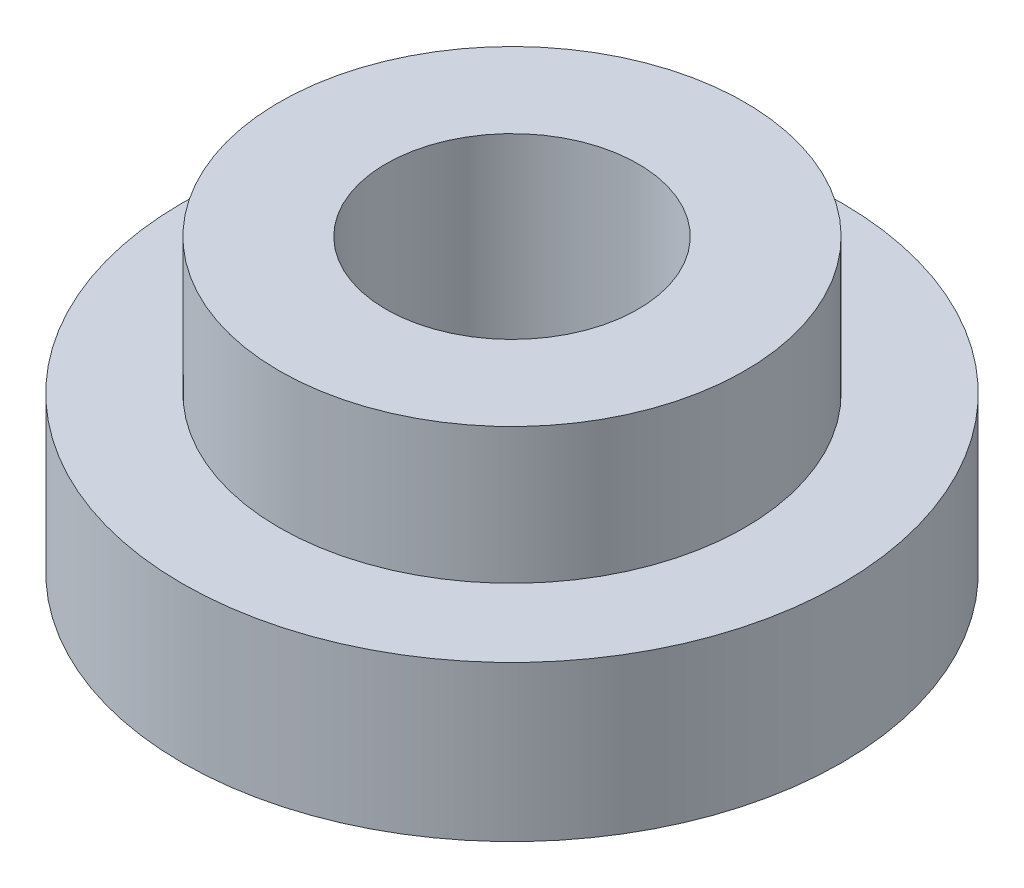
from build123d import *

# Parameters (mm, degrees)
SKETCH1_R           = 4.318
BOSS_EXTRUDE1_DEPTH = 2.032
SKETCH2_R           = 3.048
BOSS_EXTRUDE2_DEPTH = 1.778
SKETCH3_R           = 1.651
CUT_EXTRUDE1_DEPTH  = 4.81


with BuildPart() as part:
    # Sketch1 → Boss-Extrude1 (new body)
    with BuildSketch(Plane(origin=(0, 0, 0), x_dir=(1, 0, 0), z_dir=(0, 1, 0))):
        Circle(SKETCH1_R)
    extrude(amount=BOSS_EXTRUDE1_DEPTH)

    # Sketch2 → Boss-Extrude2 (add)
    with BuildSketch(Plane(origin=(0, 2.032, 0), x_dir=(1, 0, 0), z_dir=(0, 1, 0))):
        Circle(SKETCH2_R)
    extrude(amount=BOSS_EXTRUDE2_DEPTH)

    # Sketch3 → Cut-Extrude1 (cut, through all)
    with BuildSketch(Plane(origin=(0, 3.81, 0), x_dir=(1, 0, 0), z_dir=(0, 1, 0))):
        Circle(SKETCH3_R)
    extrude(amount=-CUT_EXTRUDE1_DEPTH, mode=Mode.SUBTRACT)


solid = part.part
